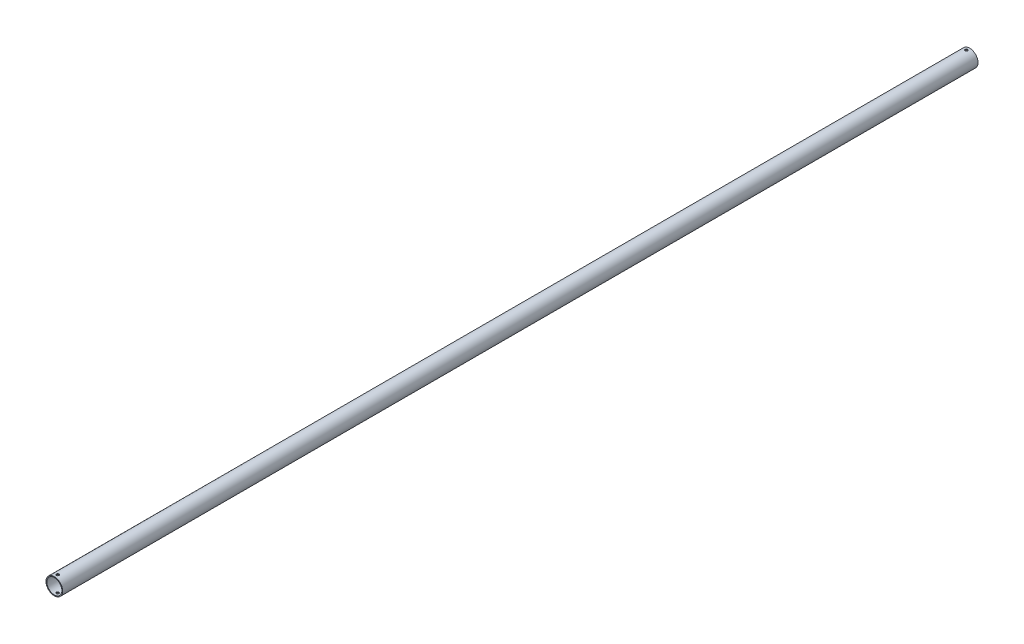
from build123d import *

# Parameters (mm, degrees)
SKETCH1_R                    = 15.875
SKETCH1_R_2                  = 14.2875
BOSS_EXTRUDE1_DEPTH          = 1739.9
F_10_0_1935_DIAMETER_HOLE1_D = 4.9149
F_10_0_1935_DIAMETER_HOLE2_D = 4.9149


with BuildPart() as part:
    # Sketch1 → Boss-Extrude1 (new body)
    with BuildSketch(Plane.XY):
        Circle(SKETCH1_R)
        Circle(SKETCH1_R_2, mode=Mode.SUBTRACT)
    extrude(amount=BOSS_EXTRUDE1_DEPTH)

    # #10 (0.1935) Diameter Hole1 (through all)
    with Locations(Plane(origin=(0, -15.875, 6.35), x_dir=(-1, 0, 0), z_dir=(0, -1, 0))):
        with Locations((0, 0)):
            Hole(F_10_0_1935_DIAMETER_HOLE1_D / 2)

    # #10 (0.1935) Diameter Hole2 (through all)
    with Locations(Plane(origin=(0, 15.875, 1733.55), x_dir=(1, 0, 0), z_dir=(0, 1, 0))):
        with Locations((0, 0)):
            Hole(F_10_0_1935_DIAMETER_HOLE2_D / 2)


solid = part.part
